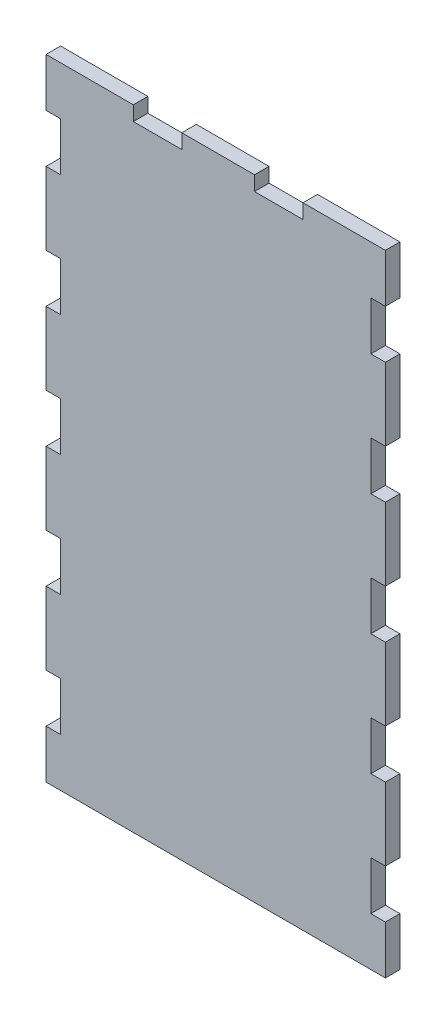
from build123d import *

# Parameters (mm, degrees)
BOSS_EXTRU_1_DEPTH = 3


with BuildPart() as part:
    # Esquisse1 → Boss.-Extru.1 (new body)
    with BuildSketch(Plane.XY):
        Polygon((31.516012245, -1.212242863), (14.516012245, -1.212242863), (14.516012245, -4.212242863), (4.516012245, -4.212242863), (4.516012245, -1.212242863), (-10.483987755, -1.212242863), (-10.483987755, -4.212242863), (-20.483987755, -4.212242863), (-20.483987755, -1.212242863), (-38.483987755, -1.212242863), (-38.483987755, -11.212242863), (-35.483987755, -11.212242863), (-35.483987755, -21.212242863), (-38.483987755, -21.212242863), (-38.483987755, -36.212242863), (-35.483987755, -36.212242863), (-35.483987755, -46.212242863), (-38.483987755, -46.212242863), (-38.483987755, -61.212242863), (-35.483987755, -61.212242863), (-35.483987755, -71.212242863), (-38.483987755, -71.212242863), (-38.483987755, -86.212242863), (-35.483987755, -86.212242863), (-35.483987755, -96.212242863), (-38.483987755, -96.212242863), (-38.483987755, -111.212242863), (-35.483987755, -111.212242863), (-35.483987755, -121.212242863), (-38.483987755, -121.212242863), (-38.483987755, -131.212242863), (31.516012245, -131.212242863), (31.516012245, -121.212242863), (28.516012245, -121.212242863), (28.516012245, -111.212242863), (31.516012245, -111.212242863), (31.516012245, -96.212242863), (28.516012245, -96.212242863), (28.516012245, -86.212242863), (31.516012245, -86.212242863), (31.516012245, -71.212242863), (28.516012245, -71.212242863), (28.516012245, -61.212242863), (31.516012245, -61.212242863), (31.516012245, -46.212242863), (28.516012245, -46.212242863), (28.516012245, -36.212242863), (31.516012245, -36.212242863), (31.516012245, -21.212242863), (28.516012245, -21.212242863), (28.516012245, -11.212242863), (31.516012245, -11.212242863), align=None)
    extrude(amount=BOSS_EXTRU_1_DEPTH)


solid = part.part
